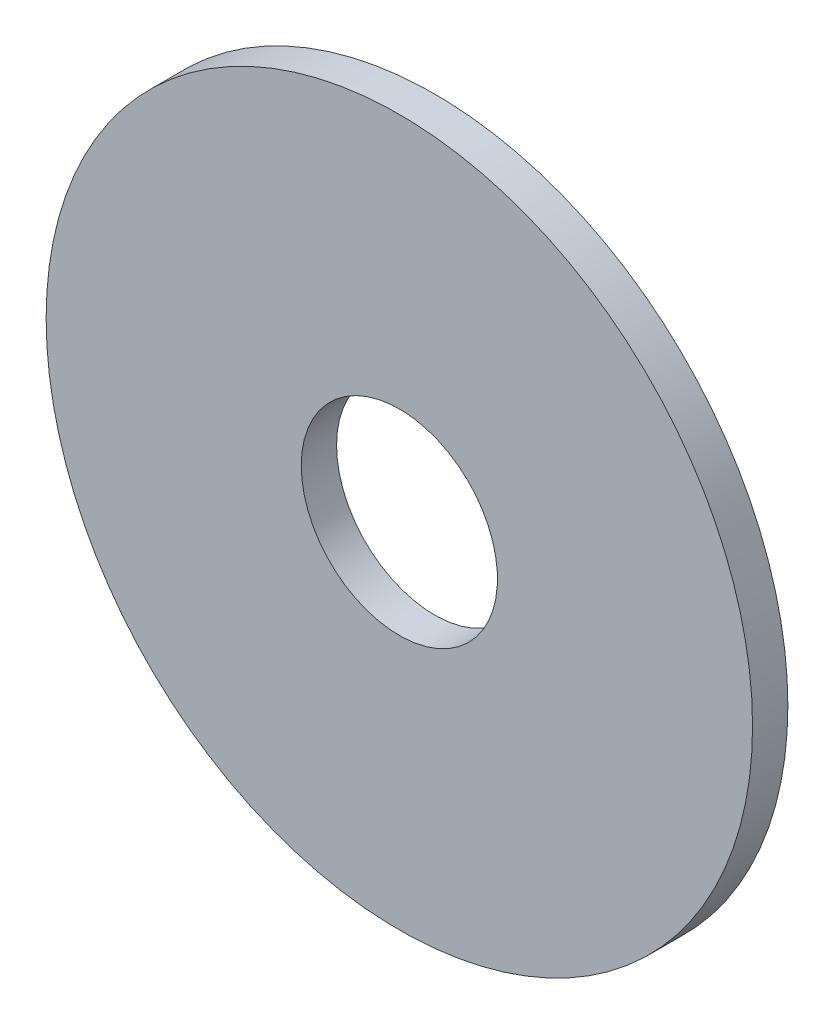
from build123d import *

# Parameters (mm, degrees)
SKETCH1_R           = 60
BOSS_EXTRUDE1_DEPTH = 6
SKETCH2_R           = 16.665
CUT_EXTRUDE1_DEPTH  = 7


with BuildPart() as part:
    # Sketch1 → Boss-Extrude1 (new body)
    with BuildSketch(Plane.XY):
        Circle(SKETCH1_R)
    extrude(amount=BOSS_EXTRUDE1_DEPTH)

    # Sketch2 → Cut-Extrude1 (cut, through all)
    with BuildSketch(Plane(origin=(0, 0, 0), x_dir=(-1, 0, 0), z_dir=(0, 0, -1))):
        Circle(SKETCH2_R)
    extrude(amount=-CUT_EXTRUDE1_DEPTH, mode=Mode.SUBTRACT)


solid = part.part
